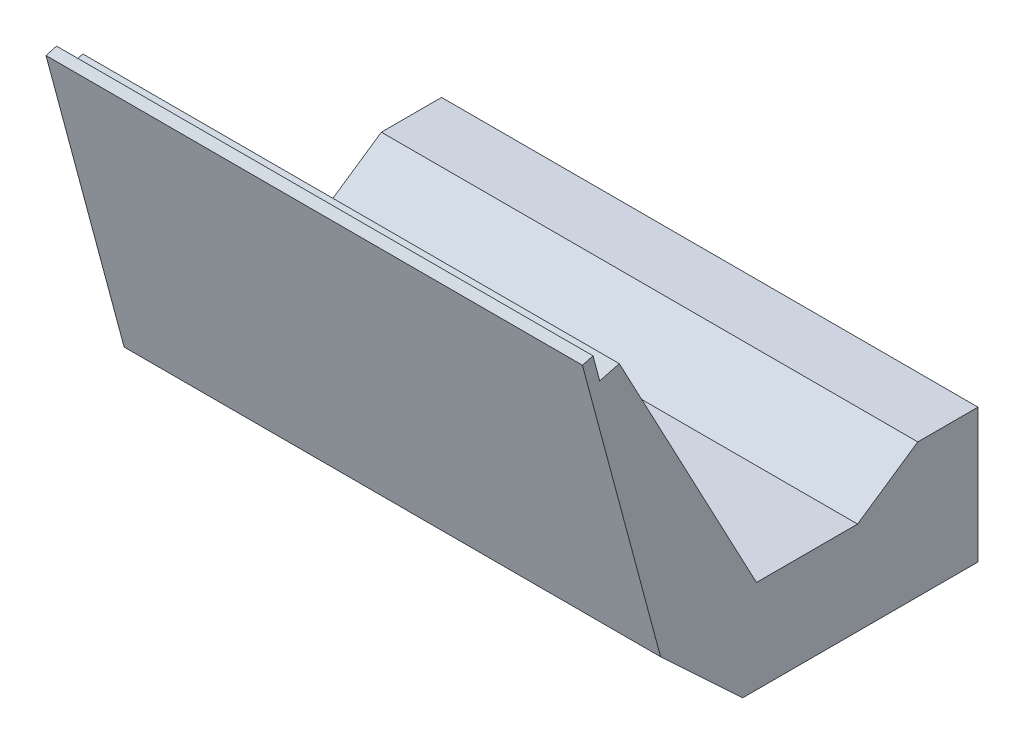
from build123d import *

# Parameters (mm, degrees)
BOSS_EXTRUDE1_DEPTH = 49


with BuildPart() as part:
    # Sketch1 → Boss-Extrude1 (new body, symmetric)
    with BuildSketch(Plane(origin=(0, 0, 0), x_dir=(0, 0, -1), z_dir=(1, 0, 0))):
        Polygon((-61.102982905, 46.194785918), (-62.332373369, 50.782933593), (-64.264225021, 50.265295502), (-49.991832107, -3), (-35, -17), (8, -17), (8, 7.5), (-3, 7.5), (-14, 0), (-32.467253687, 0), (-57.53744343, 47.150169341), align=None)
    extrude(amount=BOSS_EXTRUDE1_DEPTH, both=True)


solid = part.part
